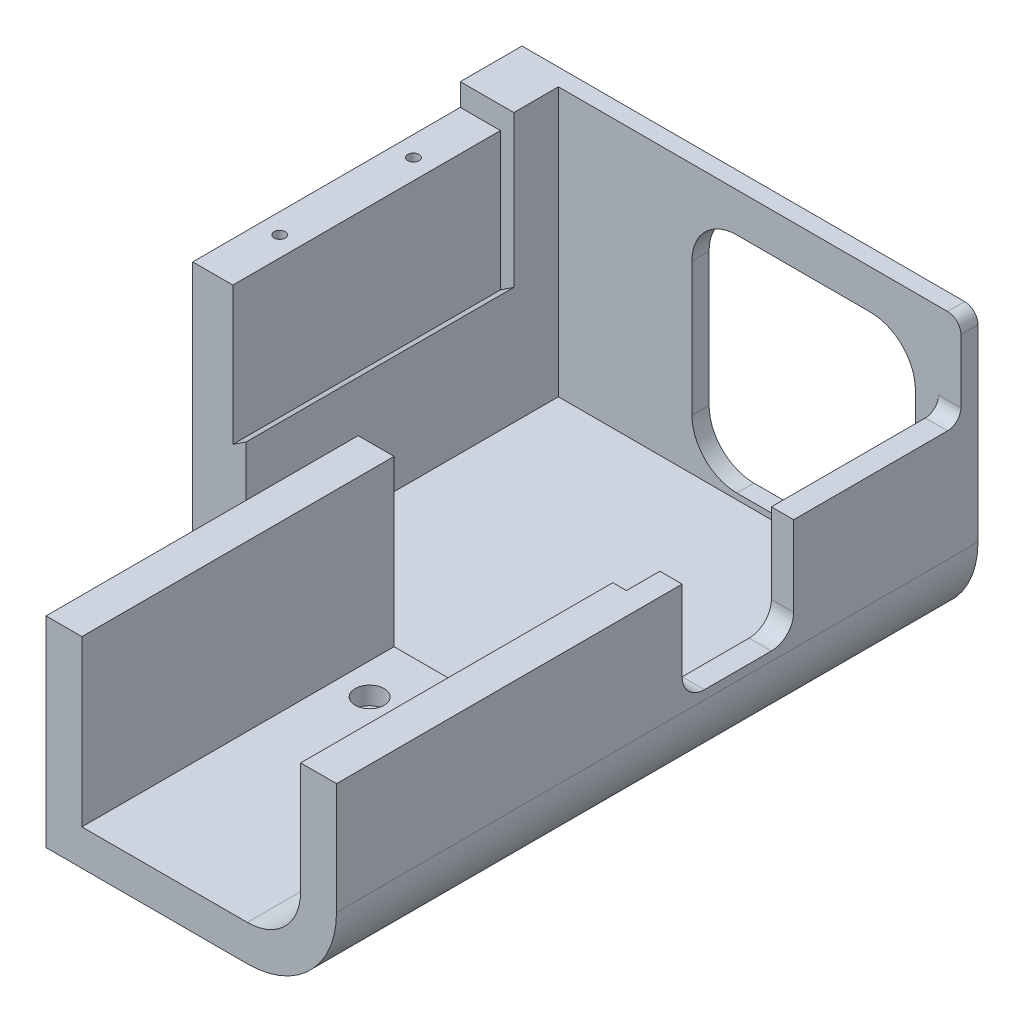
from build123d import *

# Parameters (mm, degrees)
BOSS_EXTRUDE1_DEPTH            = 70
BOSS_EXTRUDE2_DEPTH            = 70
CUT_EXTRUDE1_DEPTH             = 60
SKETCH13_W                     = 9
SKETCH13_H                     = 60
CUT_EXTRUDE3_DEPTH             = 5
SKETCH12_W                     = 25
SKETCH12_H                     = 23
CUT_EXTRUDE2_DEPTH             = 5
BOSS_EXTRUDE3_DEPTH            = 3.84
CBORE_FOR_M3_SHCS1_D           = 3.4
CBORE_FOR_M3_SHCS1_DEPTH       = 8.05
CBORE_FOR_M3_SHCS1_CBORE_D     = 6.5
CBORE_FOR_M3_SHCS1_CBORE_DEPTH = 4
CBORE_FOR_M3_SHCS1_TIP         = 1.021463052
M3X0_5_TAPPED_HOLE1_D          = 2.5
M3X0_5_TAPPED_HOLE1_DEPTH      = 14
M3X0_5_TAPPED_HOLE1_TIP        = 0.751075774
FILLET1_R                      = 10
FILLET4_R                      = 5
FILLET5_R                      = 3
TOLERANCE_BY                   = 0.05
TOLERANCE_2_BY                 = 0.05
TOLERANCE_3_BY                 = 0.05
TOLERANCE_4_BY                 = 0.05
TOLERANCE_5_BY                 = 0.05
TOLERANCE_6_BY                 = 0.05
TOLERANCE_7_BY                 = 0.05
TOLERANCE_8_BY                 = 0.05


with BuildPart() as part:
    # Sketch3 → Boss-Extrude1 (new body)
    with BuildSketch(Plane.XY):
        with BuildLine():
            Line((85.25, 15), (85.25, 40))
            Line((85.25, 40), (90.25, 40))
            Line((90.25, 40), (90.25, 15))
            ThreePointArc((90.25, 15), (84.392135624, 0.857864376), (70.25, -5))
            Line((70.25, -5), (-12, -5))
            Line((-12, -5), (-12, 60.2))
            Line((-12, 60.2), (0, 60.2))
            Line((0, 60.2), (0, 0))
            Line((0, 0), (70.25, 0))
            ThreePointArc((70.25, 0), (80.856601718, 4.393398282), (85.25, 15))
        make_face()
    extrude(amount=BOSS_EXTRUDE1_DEPTH)

    # Sketch5 → Boss-Extrude2 (add)
    with BuildSketch(Plane.XY.offset(70)):
        with BuildLine():
            Line((82.2, 15), (82.2, 40))
            Line((82.2, 40), (90.25, 40))
            Line((90.25, 40), (90.25, 15))
            ThreePointArc((90.25, 15), (84.392135624, 0.857864376), (70.25, -5))
            Line((70.25, -5), (25.1, -5))
            Line((25.1, -5), (25.1, 40))
            Line((25.1, 40), (33.15, 40))
            Line((33.15, 40), (33.15, 3.05))
            Line((33.15, 3.05), (70.25, 3.05))
            ThreePointArc((70.25, 3.05), (78.699926035, 6.550073965), (82.2, 15))
        make_face()
    extrude(amount=BOSS_EXTRUDE2_DEPTH)

    # Sketch6 → Cut-Extrude1 (cut)
    with BuildSketch(Plane.XY.offset(70)):
        Polygon((-3, 24.26), (0, 26.24), (0, 60.2), (-3, 60.2), align=None)
    extrude(amount=-CUT_EXTRUDE1_DEPTH, mode=Mode.SUBTRACT)

    # Sketch13 → Cut-Extrude3 (cut)
    with BuildSketch(Plane(origin=(0, 60.2, 0), x_dir=(1, 0, 0), z_dir=(0, 1, 0))):
        with Locations((-7.5, -40)):
            Rectangle(SKETCH13_W, SKETCH13_H)
    extrude(amount=-CUT_EXTRUDE3_DEPTH, mode=Mode.SUBTRACT)

    # Sketch12 → Cut-Extrude2 (cut)
    with BuildSketch(Plane(origin=(90.25, 0, 0), x_dir=(0, 0, -1), z_dir=(1, 0, 0))):
        with Locations((-50, 28.5)):
            Rectangle(SKETCH12_W, SKETCH12_H)
    extrude(amount=-CUT_EXTRUDE2_DEPTH, mode=Mode.SUBTRACT)

    # Sketch7 → Boss-Extrude3 (add)
    with BuildSketch(Plane.XY):
        with BuildLine():
            Line((-12, 60.2), (-12, -5))
            Line((-12, -5), (70.25, -5))
            ThreePointArc((70.25, -5), (84.392135624, 0.857864376), (90.25, 15))
            Line((90.25, 15), (90.25, 60.2))
            Line((90.25, 60.2), (-12, 60.2))
        make_face()
        with BuildLine():
            Line((70, 51.37), (40, 51.37))
            ThreePointArc((40, 51.37), (32.928932188, 48.441067812), (30, 41.37))
            Line((30, 41.37), (30, 11.37))
            ThreePointArc((30, 11.37), (32.928932188, 4.298932188), (40, 1.37))
            Line((40, 1.37), (70, 1.37))
            ThreePointArc((70, 1.37), (77.071067812, 4.298932188), (80, 11.37))
            Line((80, 11.37), (80, 41.37))
            ThreePointArc((80, 41.37), (77.071067812, 48.441067812), (70, 51.37))
        make_face(mode=Mode.SUBTRACT)
    extrude(amount=-BOSS_EXTRUDE3_DEPTH)

    # CBORE for M3 SHCS1
    with Locations(Plane(origin=(0, 3.05, 0), x_dir=(1, 0, 0), z_dir=(0, 1, 0))):
        with Locations((40.175, -82.5), (55.175, -82.5)):
            CounterBoreHole(CBORE_FOR_M3_SHCS1_D / 2, CBORE_FOR_M3_SHCS1_CBORE_D / 2, CBORE_FOR_M3_SHCS1_CBORE_DEPTH, depth=CBORE_FOR_M3_SHCS1_DEPTH)
            with Locations((0, 0, -(CBORE_FOR_M3_SHCS1_DEPTH + CBORE_FOR_M3_SHCS1_TIP / 2))):  # 118° drill point
                Cone(0, CBORE_FOR_M3_SHCS1_D / 2, CBORE_FOR_M3_SHCS1_TIP, mode=Mode.SUBTRACT)

    # M3x0.5 Tapped Hole1
    with Locations(Plane(origin=(0, 55.2, 0), x_dir=(1, 0, 0), z_dir=(0, 1, 0))):
        with Locations((-7.5, -25), (-7.5, -55)):
            Hole(M3X0_5_TAPPED_HOLE1_D / 2, depth=M3X0_5_TAPPED_HOLE1_DEPTH)
            with Locations((0, 0, -(M3X0_5_TAPPED_HOLE1_DEPTH + M3X0_5_TAPPED_HOLE1_TIP / 2))):  # 118° drill point
                Cone(0, M3X0_5_TAPPED_HOLE1_D / 2, M3X0_5_TAPPED_HOLE1_TIP, mode=Mode.SUBTRACT)

    # Fillet1
    fillet1_edges = [part.edges().sort_by_distance(p)[0] for p in [
        (25.1, -2.5, 70),
    ]]
    fillet(fillet1_edges, radius=FILLET1_R)

    # Fillet4
    fillet4_edges = [part.edges().sort_by_distance(p)[0] for p in [
        (87.75, 17, 37.5),
        (87.75, 17, 62.5),
    ]]
    fillet(fillet4_edges, radius=FILLET4_R)

    # Fillet5
    fillet5_edges = [part.edges().sort_by_distance(p)[0] for p in [
        (87.75, 40, 0),
        (90.25, 60.2, -1.92),
    ]]
    fillet(fillet5_edges, radius=FILLET5_R)

    # Tolerance: a curved face moved inward by 0.05
    add(Solid.thicken(part.faces().sort_by_distance((32.928932188, 4.298932188, -1.92))[0], -TOLERANCE_BY), mode=Mode.SUBTRACT)

    # Tolerance 2: a face moved inward by 0.05
    extrude(part.faces().sort_by_distance((30, 26.37, -1.92))[0], amount=TOLERANCE_2_BY, dir=(-1, 0, 0), mode=Mode.SUBTRACT)

    # Tolerance 3: a curved face moved inward by 0.05
    add(Solid.thicken(part.faces().sort_by_distance((32.928932188, 48.441067812, -1.92))[0], -TOLERANCE_3_BY), mode=Mode.SUBTRACT)

    # Tolerance 4: a face moved inward by 0.05
    extrude(part.faces().sort_by_distance((55, 51.37, -1.92))[0], amount=TOLERANCE_4_BY, dir=(0, 1, 0), mode=Mode.SUBTRACT)

    # Tolerance 5: a curved face moved inward by 0.05
    add(Solid.thicken(part.faces().sort_by_distance((77.071067812, 48.441067812, -1.92))[0], -TOLERANCE_5_BY), mode=Mode.SUBTRACT)

    # Tolerance 6: a face moved inward by 0.05
    extrude(part.faces().sort_by_distance((80, 26.37, -1.92))[0], amount=TOLERANCE_6_BY, dir=(1, 0, 0), mode=Mode.SUBTRACT)

    # Tolerance 7: a curved face moved inward by 0.05
    add(Solid.thicken(part.faces().sort_by_distance((77.071067812, 4.298932188, -1.92))[0], -TOLERANCE_7_BY), mode=Mode.SUBTRACT)

    # Tolerance 8: a face moved inward by 0.05
    extrude(part.faces().sort_by_distance((55, 1.37, -1.92))[0], amount=TOLERANCE_8_BY, dir=(0, -1, 0), mode=Mode.SUBTRACT)


solid = part.part
